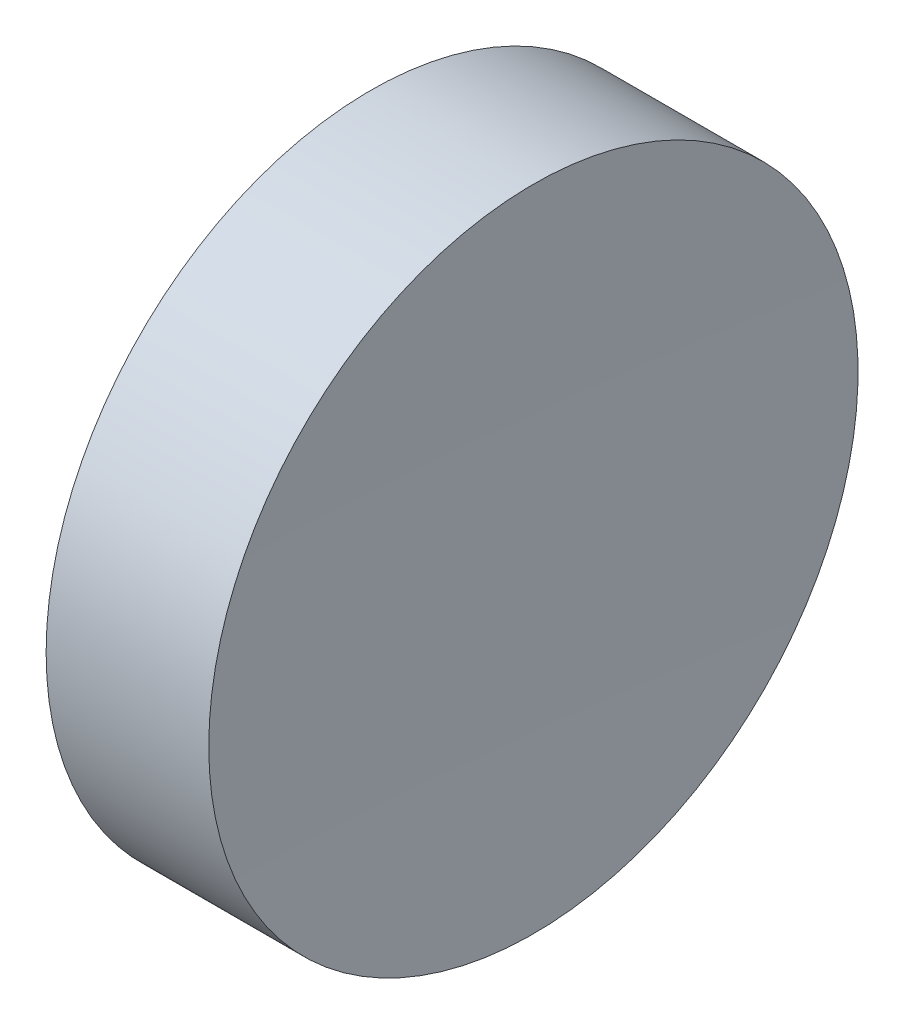
from build123d import *


with BuildPart() as part:
    # 草图1 → 旋转1 (revolve)
    with BuildSketch(Plane(origin=(0, 0, 0), x_dir=(1, 0, 0), z_dir=(0, 1, 0)), mode=Mode.PRIVATE) as revolve_1_sk:
        with BuildLine():
            Line((0, 0), (3.08, 0))
            ThreePointArc((3.08, 0), (3.105209506, 3.175400251), (3.180831668, 6.35))
            Line((3.180831668, 6.35), (0, 6.35))
            Line((0, 6.35), (0, 0))
        make_face()
    revolve(revolve_1_sk.sketch.rotate(Axis((0, 0, 0), (1, 0, 0)), 180), axis=Axis((0, 0, 0), (1, 0, 0)))  # turned: the seam where the file's is


solid = part.part
